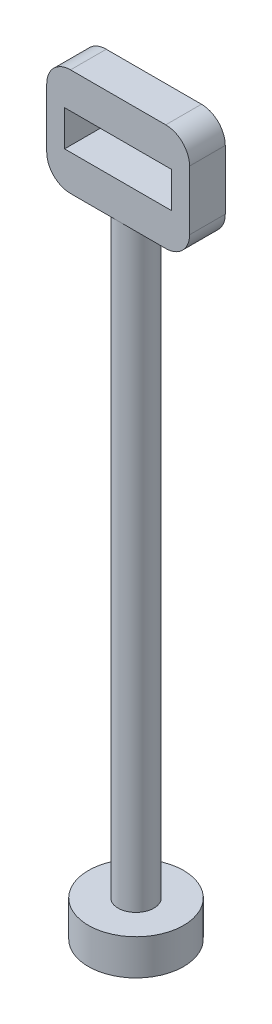
from build123d import *

# Parameters (mm, degrees)
SKETCH1_R           = 1.5
BOSS_EXTRUDE1_DEPTH = 50
SKETCH2_R           = 4
BOSS_EXTRUDE2_DEPTH = 3
BOSS_EXTRUDE3_DEPTH = 3
SKETCH5_W           = 4.5
SKETCH5_H           = 3
CUT_EXTRUDE1_DEPTH  = 4
FILLET1_R           = 2


with BuildPart() as part:
    # Sketch1 → Boss-Extrude1 (new body)
    with BuildSketch(Plane(origin=(0, 0, 0), x_dir=(1, 0, 0), z_dir=(0, 1, 0))):
        Circle(SKETCH1_R)
    extrude(amount=BOSS_EXTRUDE1_DEPTH)

    # Sketch2 → Boss-Extrude2 (add)
    with BuildSketch(Plane(origin=(0, 0, 0), x_dir=(-1, 0, 0), z_dir=(0, -1, 0))):
        Circle(SKETCH2_R)
    extrude(amount=BOSS_EXTRUDE2_DEPTH)

    # Sketch4 → Boss-Extrude3 (add)
    with BuildSketch(Plane.XY.offset(1.5)):
        Polygon((0, 50), (6, 50), (6, 59), (-6, 59), (-6, 50), align=None)
    extrude(amount=-BOSS_EXTRUDE3_DEPTH)

    # Sketch5 → Cut-Extrude1 (cut)
    with BuildSketch(Plane.XY.offset(1.5)):
        with Locations((-2.25, 54.5)):
            Rectangle(SKETCH5_W, SKETCH5_H)
        with Locations((2.25, 54.5)):
            Rectangle(SKETCH5_W, SKETCH5_H)
    extrude(amount=-CUT_EXTRUDE1_DEPTH, mode=Mode.SUBTRACT)

    # Fillet1
    fillet1_edges = [part.edges().sort_by_distance(p)[0] for p in [
        (6, 50, 0),
        (-6, 50, 0),
        (-6, 59, 0),
        (6, 59, 0),
    ]]
    fillet(fillet1_edges, radius=FILLET1_R)


solid = part.part
